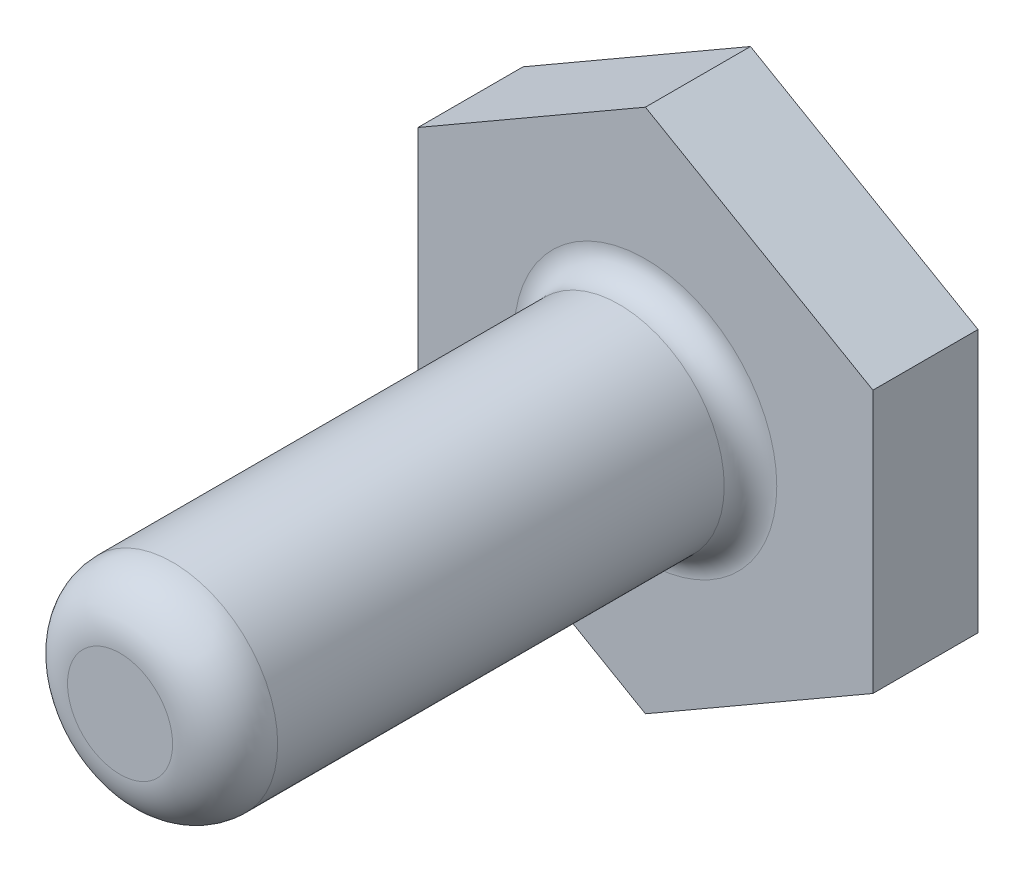
from build123d import *

# Parameters (mm, degrees)
BOSS_EXTRUDE2_DEPTH = 4
SKETCH4_R           = 4
BOSS_EXTRUDE3_DEPTH = 20
FILLET1_R           = 2
FILLET3_R           = 1


with BuildPart() as part:
    # Sketch1 → Boss-Extrude2 (new body)
    with BuildSketch(Plane.XY):
        Polygon((-0.353108988, 3.18967376), (-0.353108988, 13.18967376), (-9.013363026, 18.18967376), (-17.673617064, 13.18967376), (-17.673617064, 3.18967376), (-9.013363026, -1.81032624), align=None)
    extrude(amount=BOSS_EXTRUDE2_DEPTH)

    # Sketch4 → Boss-Extrude3 (add)
    with BuildSketch(Plane.XY.offset(4)):
        with Locations((-9.013363026, 8.18967376)):
            Circle(SKETCH4_R)
    extrude(amount=BOSS_EXTRUDE3_DEPTH)

    # Fillet1
    fillet1_edges = [part.edges().sort_by_distance(p)[0] for p in [
        (-13.013363026, 8.18967376, 24),
    ]]
    fillet(fillet1_edges, radius=FILLET1_R)

    # Fillet3
    fillet3_edges = [part.edges().sort_by_distance(p)[0] for p in [
        (-13.013363026, 8.18967376, 4),
    ]]
    fillet(fillet3_edges, radius=FILLET3_R)


solid = part.part
